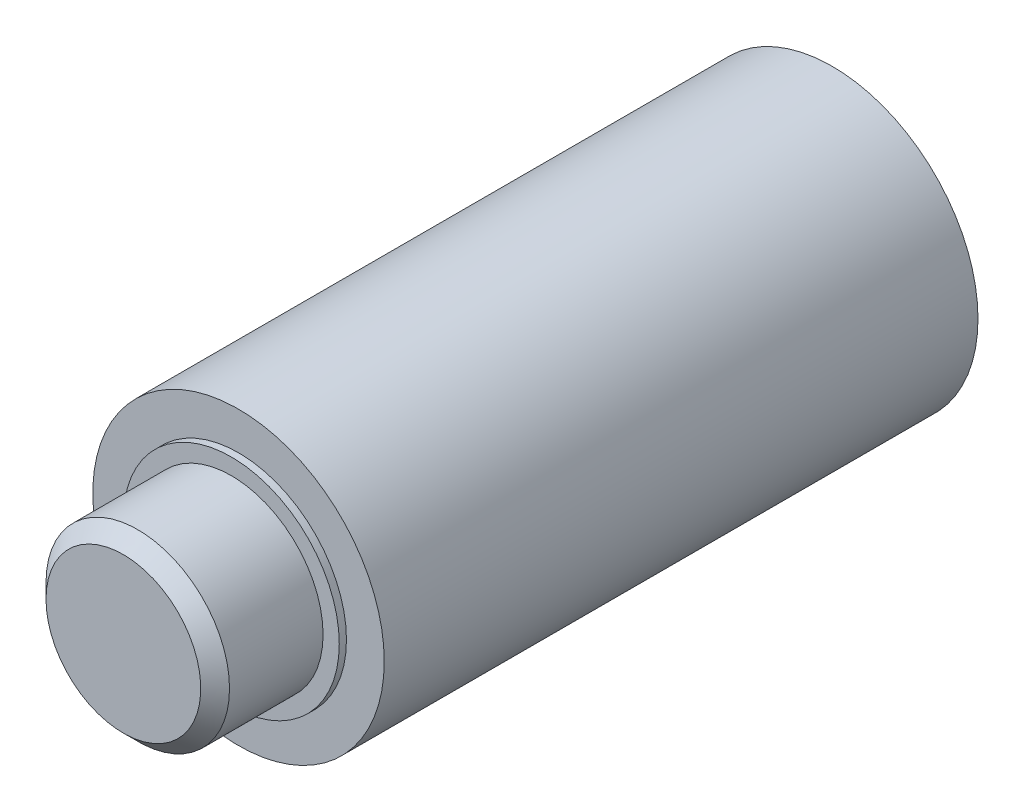
from build123d import *

# Parameters (mm, degrees)
CHAMFER1_SIZE         = 0.4
BOSS_EXTRUDE1_DEPTH   = 1.5
CHAMFER2_SIZE         = 1
CHAMFER2_SIZE2        = 0.05
CHAMFER2_PART_2_SIZE  = 1
CHAMFER2_PART_2_SIZE2 = 0.05


with BuildPart() as part:
    # Sketch1 → Revolve1 (revolve)
    with BuildSketch(Plane(origin=(0, 0, 0), x_dir=(1, 0, 0), z_dir=(0, 1, 0))):
        Polygon((0, -19.7), (0, -6.8), (-3.25, -6.8), (-3.25, 0), (-4.05, 0), (-4.05, -16.5), (-3, -16.5), (-3, -16.7), (-2.55, -16.7), (-2.55, -19.7), align=None)
    revolve(axis=Axis((0, 0, 19.7), (0, 0, -1)))

    # Chamfer1
    chamfer1_edges = [part.edges().sort_by_distance(p)[0] for p in [
        (2.55, 0, 19.7),
    ]]
    chamfer(chamfer1_edges, length=CHAMFER1_SIZE)

    # Sketch2 → Boss-Extrude1 (add)
    with BuildSketch(Plane.XY.offset(6.8)):
        with BuildLine():
            Line((0.525, 3.207315856), (0.525, -3.207315856))
            ThreePointArc((0.525, -3.207315856), (0, -3.25), (-0.525, -3.207315856))
            Line((-0.525, -3.207315856), (-0.525, 3.207315856))
            ThreePointArc((-0.525, 3.207315856), (0, 3.25), (0.525, 3.207315856))
        make_face()
    extrude(amount=-BOSS_EXTRUDE1_DEPTH)

    # Chamfer2
    chamfer2_edges = [part.edges().sort_by_distance(p)[0] for p in [
        (-0.525, 0, 6.8),
    ]]
    chamfer2_side = [part.faces().sort_by_distance(p)[0] for p in [
        (-0.525, 0, 6.05),
    ]]
    chamfer(chamfer2_edges, length=CHAMFER2_SIZE, length2=CHAMFER2_SIZE2, reference=chamfer2_side[0])

    # Chamfer2 part 2
    chamfer2_part_2_edges = [part.edges().sort_by_distance(p)[0] for p in [
        (0.525, 0, 6.8),
    ]]
    chamfer2_part_2_side = [part.faces().sort_by_distance(p)[0] for p in [
        (0.525, 0, 6.05),
    ]]
    chamfer(chamfer2_part_2_edges, length=CHAMFER2_PART_2_SIZE, length2=CHAMFER2_PART_2_SIZE2, reference=chamfer2_part_2_side[0])


solid = part.part
